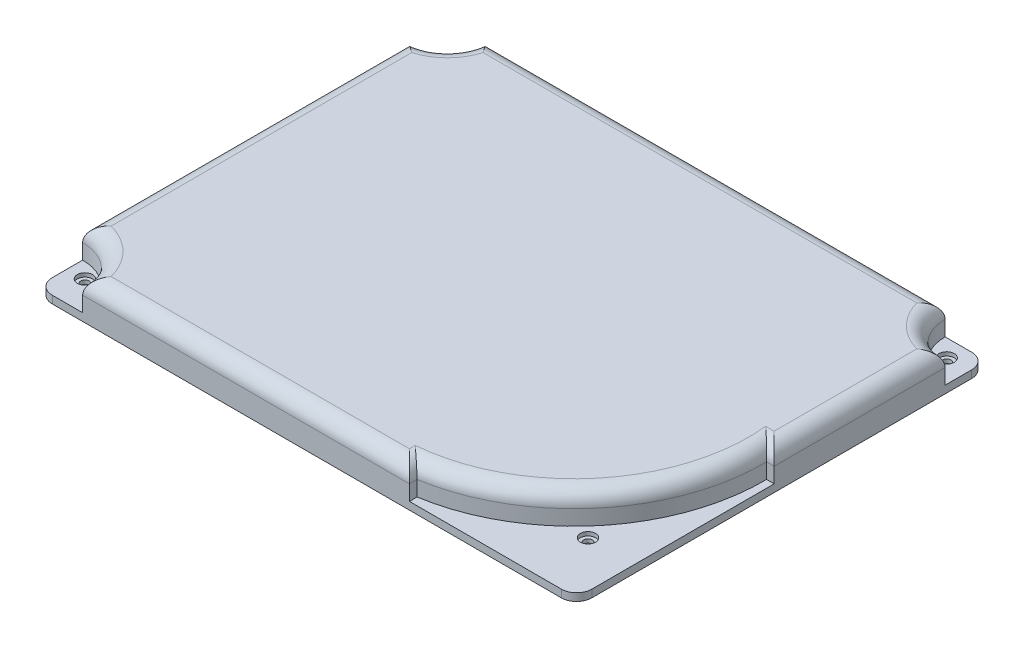
from build123d import *

# Parameters (mm, degrees)
SKETCH1_W                         = 71
SKETCH1_H                         = 54
BOSS_EXTRUDE1_DEPTH               = 5
M1_4X0_3_TAPPED_HOLE1_D           = 1.1
M1_4X0_3_TAPPED_HOLE1_CSINK_D     = 1.45
M1_4X0_3_TAPPED_HOLE1_CSINK_ANGLE = 90
CUT_EXTRUDE1_DEPTH                = 4
SKETCH5_R                         = 6
SKETCH5_R_2                       = 5
SKETCH5_R_3                       = 5.5
CUT_EXTRUDE2_DEPTH                = 4
FILLET1_R                         = 2
FILLET2_R                         = 2
SKETCH6_R                         = 1
CUT_EXTRUDE3_DEPTH                = 0.5


with BuildPart() as part:
    # Sketch1 → Boss-Extrude1 (new body)
    with BuildSketch(Plane(origin=(0, 0, 0), x_dir=(1, 0, 0), z_dir=(0, 1, 0))):
        Rectangle(SKETCH1_W, SKETCH1_H)
    extrude(amount=BOSS_EXTRUDE1_DEPTH)

    # M1.4x0.3 Tapped Hole1 (through all)
    with Locations(Plane(origin=(0, 5, 0), x_dir=(1, 0, 0), z_dir=(0, 1, 0))):
        with Locations((-33.2, 24.7), (32.5, 24.7), (-33.2, -23), (29.4, -19.4)):
            CounterSinkHole(M1_4X0_3_TAPPED_HOLE1_D / 2, M1_4X0_3_TAPPED_HOLE1_CSINK_D / 2, counter_sink_angle=M1_4X0_3_TAPPED_HOLE1_CSINK_ANGLE)

    # Sketch4 → Cut-Extrude1 (cut)
    with BuildSketch(Plane.XZ):
        with BuildLine():
            Line((-7.748076809, 19), (-33.5, 19))
            Line((-33.5, 19), (-33.5, -20))
            Line((-33.5, -20), (-6.5, -20))
            ThreePointArc((-6.5, -20), (33.487208249, 0.799639875), (-7.748076809, 19))
        make_face()
    extrude(amount=-CUT_EXTRUDE1_DEPTH, mode=Mode.SUBTRACT)

    # Sketch5 → Cut-Extrude2 (cut)
    with BuildSketch(Plane(origin=(0, 5, 0), x_dir=(1, 0, 0), z_dir=(0, 1, 0))):
        with Locations((-35.5, -27)):
            Circle(SKETCH5_R)
        with Locations((-35.5, 27)):
            Circle(SKETCH5_R_2)
        with Locations((35.5, 27)):
            Circle(SKETCH5_R_3)
        with BuildLine():
            Line((34.5, -1), (35.5, -1))
            Line((35.5, -1), (35.5, -27))
            Line((35.5, -27), (13.5, -27))
            Line((13.5, -27), (13.5, -26))
            ThreePointArc((13.5, -26), (28.644692027, -17.401541303), (34.5, -1))
        make_face()
    extrude(amount=-CUT_EXTRUDE2_DEPTH, mode=Mode.SUBTRACT)

    # Fillet1
    fillet1_edges = [part.edges().sort_by_distance(p)[0] for p in [
        (35.5, 0.5, 27),
        (-35.5, 0.5, 27),
        (-35.5, 0.5, -27),
        (35.5, 0.5, -27),
    ]]
    fillet(fillet1_edges, radius=FILLET1_R)

    # Fillet2
    fillet2_edges = [part.edges().sort_by_distance(p)[0] for p in [
        (35.5, 5, -10.25),
        (-0.25, 5, -27),
        (-35.5, 5, -0.5),
        (-8, 5, 27),
        (28.644692027, 5, 17.401541303),
        (13.5, 5, 26.5),
        (35, 5, 1),
        (31.610912703, 5, -23.110912703),
        (-31.964466094, 5, -23.464466094),
        (-31.257359313, 5, 22.757359313),
    ]]
    fillet(fillet2_edges, radius=FILLET2_R)

    # Sketch6 → Cut-Extrude3 (cut)
    with BuildSketch(Plane(origin=(0, 1, 0), x_dir=(1, 0, 0), z_dir=(0, 1, 0))):
        with Locations((-33.2, 24.7)):
            Circle(SKETCH6_R)
        with Locations((32.5, 24.7)):
            Circle(SKETCH6_R)
        with Locations((29.4, -19.4)):
            Circle(SKETCH6_R)
        with Locations((-33.2, -23)):
            Circle(SKETCH6_R)
    extrude(amount=-CUT_EXTRUDE3_DEPTH, mode=Mode.SUBTRACT)


solid = part.part
